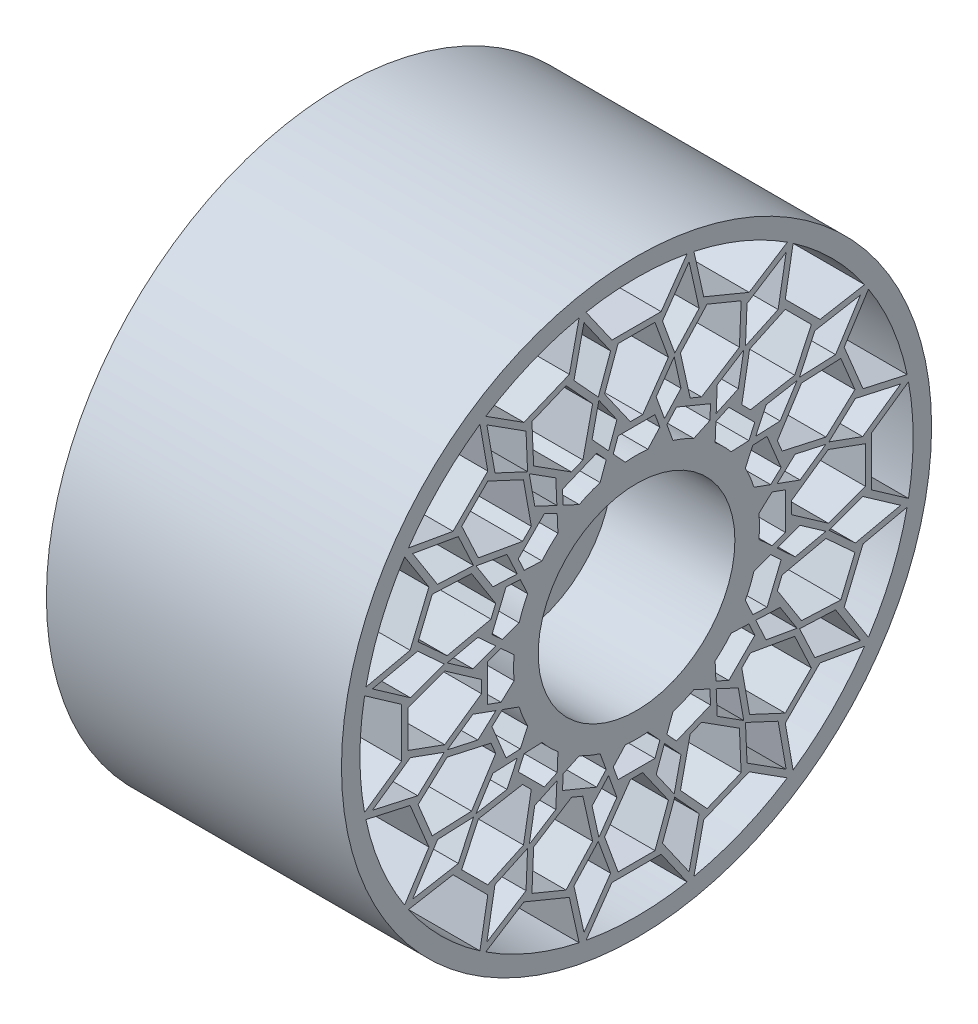
from build123d import *

# Parameters (mm, degrees)
SKETCH1_R           = 152.4
SKETCH1_R_2         = 50.8
BOSS_EXTRUDE3_DEPTH = 63.5
CUT_EXTRUDE1_DEPTH  = 64.5
SKETCH4_R           = 152.4
BOSS_EXTRUDE5_DEPTH = 88.9


with BuildPart() as part:
    # Sketch1 → Boss-Extrude3 (new body)
    with BuildSketch(Plane(origin=(0, 0, 0), x_dir=(0, 0, -1), z_dir=(1, 0, 0))):
        Circle(SKETCH1_R)
        Circle(SKETCH1_R_2, mode=Mode.SUBTRACT)
    extrude(amount=BOSS_EXTRUDE3_DEPTH)

    # Sketch2 → Cut-Extrude1 (cut, through all)
    with BuildSketch(Plane(origin=(63.5, 0, 0), x_dir=(0, 0, -1), z_dir=(1, 0, 0))):
        with BuildLine():
            ThreePointArc((-26.097684485, 140.471265708), (0, 142.875), (26.097684485, 140.471265708))
            Line((26.097684485, 140.471265708), (12.7, 121.337389315))
            Line((12.7, 121.337389315), (-12.7, 121.337389315))
            Line((-12.7, 121.337389315), (-26.097684485, 140.471265708))
        make_face()
        Polygon((3.175, 80.062389315), (-3.175, 80.062389315), (-16.477553736, 99.060404918), (-9.525, 118.162389315), (9.525, 118.162389315), (16.477553736, 99.060404918), align=None)
        with BuildLine():
            Line((9.525, 76.887389315), (-9.525, 76.887389315))
            Line((-9.525, 76.887389315), (-12.031006336, 70.002193495))
            Line((-12.031006336, 70.002193495), (-5.827314658, 63.23205203))
            ThreePointArc((-5.827314658, 63.23205203), (0, 63.5), (5.827314658, 63.23205203))
            Line((5.827314658, 63.23205203), (12.031006336, 70.002193495))
            Line((12.031006336, 70.002193495), (9.525, 76.887389315))
        make_face()
        with BuildLine():
            Line((20.623577502, 74.67974499), (15.673479171, 69.2776606))
            Line((15.673479171, 69.2776606), (18.814121964, 60.648815444))
            ThreePointArc((18.814121964, 60.648815444), (24.300397955, 58.666350314), (29.581595449, 56.188781894))
            Line((29.581595449, 56.188781894), (37.903880189, 60.069527002))
            Line((37.903880189, 60.069527002), (38.223482596, 67.389625603))
            Line((38.223482596, 67.389625603), (20.623577502, 74.67974499))
        make_face()
        Polygon((53.132050408, 85.214193765), (33.571867462, 72.752982915), (27.705232431, 75.18302271), (22.685501123, 97.825567407), (36.418836172, 112.812872694), (54.018741267, 105.522753308), align=None)
        with BuildLine():
            ThreePointArc((29.644909568, 139.765678769), (54.675895399, 131.999288208), (77.867142651, 119.791375818))
            Line((77.867142651, 119.791375818), (58.16707868, 107.241050926))
            Line((58.16707868, 107.241050926), (34.700538554, 116.961210108))
            Line((34.700538554, 116.961210108), (29.644909568, 139.765678769))
        make_face()
        with BuildLine():
            ThreePointArc((80.874334871, 117.782034216), (101.027881362, 101.027881362), (117.782034216, 80.874334871))
            Line((117.782034216, 80.874334871), (94.778746917, 76.818234675))
            Line((94.778746917, 76.818234675), (76.818234675, 94.778746917))
            Line((76.818234675, 94.778746917), (80.874334871, 117.782034216))
        make_face()
        Polygon((81.697674049, 58.39489408), (58.857722433, 54.367594373), (54.367594373, 58.857722433), (58.39489408, 81.697674049), (76.818234675, 90.288618857), (90.288618857, 76.818234675), align=None)
        with BuildLine():
            Line((47.632402282, 61.102786463), (40.991819554, 58.006231883))
            Line((40.991819554, 58.006231883), (40.591279067, 48.83234649))
            ThreePointArc((40.591279067, 48.83234649), (44.901280605, 44.901280605), (48.83234649, 40.591279067))
            Line((48.83234649, 40.591279067), (58.006231883, 40.991819554))
            Line((58.006231883, 40.991819554), (61.102786463, 47.632402282))
            Line((61.102786463, 47.632402282), (47.632402282, 61.102786463))
        make_face()
        Polygon((97.825567407, 22.685501123), (75.18302271, 27.705232431), (72.752982915, 33.571867462), (85.214193765, 53.132050408), (105.522753308, 54.018741267), (112.812872694, 36.418836172), align=None)
        with BuildLine():
            ThreePointArc((119.791375818, 77.867142651), (131.999288208, 54.675895399), (139.765678769, 29.644909568))
            Line((139.765678769, 29.644909568), (116.961210108, 34.700538554))
            Line((116.961210108, 34.700538554), (107.241050926, 58.16707868))
            Line((107.241050926, 58.16707868), (119.791375818, 77.867142651))
        make_face()
        with BuildLine():
            Line((67.389625603, 38.223482596), (60.069527002, 37.903880189))
            Line((60.069527002, 37.903880189), (56.188781894, 29.581595449))
            ThreePointArc((56.188781894, 29.581595449), (58.666350314, 24.300397955), (60.648815444, 18.814121964))
            Line((60.648815444, 18.814121964), (69.2776606, 15.673479171))
            Line((69.2776606, 15.673479171), (74.67974499, 20.623577502))
            Line((74.67974499, 20.623577502), (67.389625603, 38.223482596))
        make_face()
        Polygon((99.060404918, -16.477553736), (80.062389315, -3.175), (80.062389315, 3.175), (99.060404918, 16.477553736), (118.162389315, 9.525), (118.162389315, -9.525), align=None)
        with BuildLine():
            ThreePointArc((140.471265708, 26.097684485), (142.875, 0), (140.471265708, -26.097684485))
            Line((140.471265708, -26.097684485), (121.337389315, -12.7))
            Line((121.337389315, -12.7), (121.337389315, 12.7))
            Line((121.337389315, 12.7), (140.471265708, 26.097684485))
        make_face()
        with BuildLine():
            ThreePointArc((139.765678769, -29.644909568), (131.999288208, -54.675895399), (119.791375818, -77.867142651))
            Line((119.791375818, -77.867142651), (107.241050926, -58.16707868))
            Line((107.241050926, -58.16707868), (116.961210108, -34.700538554))
            Line((116.961210108, -34.700538554), (139.765678769, -29.644909568))
        make_face()
        Polygon((85.214193765, -53.132050408), (72.752982915, -33.571867462), (75.18302271, -27.705232431), (97.825567407, -22.685501123), (112.812872694, -36.418836172), (105.522753308, -54.018741267), align=None)
        with BuildLine():
            Line((74.67974499, -20.623577502), (69.2776606, -15.673479171))
            Line((69.2776606, -15.673479171), (60.648815444, -18.814121964))
            ThreePointArc((60.648815444, -18.814121964), (58.666350314, -24.300397955), (56.188781894, -29.581595449))
            Line((56.188781894, -29.581595449), (60.069527002, -37.903880189))
            Line((60.069527002, -37.903880189), (67.389625603, -38.223482596))
            Line((67.389625603, -38.223482596), (74.67974499, -20.623577502))
        make_face()
        with BuildLine():
            Line((61.102786463, -47.632402282), (58.006231883, -40.991819554))
            Line((58.006231883, -40.991819554), (48.83234649, -40.591279067))
            ThreePointArc((48.83234649, -40.591279067), (44.901280605, -44.901280605), (40.591279067, -48.83234649))
            Line((40.591279067, -48.83234649), (40.991819554, -58.006231883))
            Line((40.991819554, -58.006231883), (47.632402282, -61.102786463))
            Line((47.632402282, -61.102786463), (61.102786463, -47.632402282))
        make_face()
        Polygon((58.39489408, -81.697674049), (54.367594373, -58.857722433), (58.857722433, -54.367594373), (81.697674049, -58.39489408), (90.288618857, -76.818234675), (76.818234675, -90.288618857), align=None)
        Polygon((41.6973225, 74.164905949), (41.147952433, 61.582262732), (52.562564142, 66.904983587), (55.379657648, 82.88151477), align=None)
        Polygon((57.077106506, 102.782099343), (56.266154796, 84.208251511), (73.115814864, 92.065377038), (77.274262751, 115.64910694), align=None)
        Polygon((13.399363914, 116.800740918), (19.758046068, 99.330405283), (32.318310369, 113.037528491), (27.135112552, 136.417422958), align=None)
        Polygon((92.065377038, 73.115814864), (84.208251511, 56.266154796), (102.782099343, 57.077106506), (115.64910694, 77.274262751), align=None)
        Polygon((66.904983587, 52.562564142), (61.582262732, 41.147952433), (74.164905949, 41.6973225), (82.88151477, 55.379657648), align=None)
        Polygon((113.037528491, 32.318310369), (99.330405283, 19.758046068), (116.800740918, 13.399363914), (136.417422958, 27.135112552), align=None)
        Polygon((116.800740918, -13.399363914), (99.330405283, -19.758046068), (113.037528491, -32.318310369), (136.417422958, -27.135112552), align=None)
        Polygon((84.476313131, -10.141622048), (72.641231776, -14.449239382), (81.926967419, -22.958048426), (97.765412591, -19.446749666), align=None)
        Polygon((81.926967419, 22.958048426), (72.641231776, 14.449239382), (84.476313131, 10.141622048), (97.765412591, 19.446749666), align=None)
        with BuildLine():
            Line((76.887389315, 9.525), (70.002193495, 12.031006336))
            Line((70.002193495, 12.031006336), (63.23205203, 5.827314658))
            ThreePointArc((63.23205203, 5.827314658), (63.5, 0), (63.23205203, -5.827314658))
            Line((63.23205203, -5.827314658), (70.002193495, -12.031006336))
            Line((70.002193495, -12.031006336), (76.887389315, -9.525))
            Line((76.887389315, -9.525), (76.887389315, 9.525))
        make_face()
        Polygon((102.782099343, -57.077106506), (84.208251511, -56.266154796), (92.065377038, -73.115814864), (115.64910694, -77.274262751), align=None)
        Polygon((74.164905949, -41.6973225), (61.582262732, -41.147952433), (66.904983587, -52.562564142), (82.88151477, -55.379657648), align=None)
        with BuildLine():
            ThreePointArc((117.782034216, -80.874334871), (101.027881362, -101.027881362), (80.874334871, -117.782034216))
            Line((80.874334871, -117.782034216), (76.818234675, -94.778746917))
            Line((76.818234675, -94.778746917), (94.778746917, -76.818234675))
            Line((94.778746917, -76.818234675), (117.782034216, -80.874334871))
        make_face()
        Polygon((73.115814864, -92.065377038), (56.266154796, -84.208251511), (57.077106506, -102.782099343), (77.274262751, -115.64910694), align=None)
        with BuildLine():
            ThreePointArc((77.867142651, -119.791375818), (54.675895399, -131.999288208), (29.644909568, -139.765678769))
            Line((29.644909568, -139.765678769), (34.700538554, -116.961210108))
            Line((34.700538554, -116.961210108), (58.16707868, -107.241050926))
            Line((58.16707868, -107.241050926), (77.867142651, -119.791375818))
        make_face()
        Polygon((22.685501123, -97.825567407), (27.705232431, -75.18302271), (33.571867462, -72.752982915), (53.132050408, -85.214193765), (54.018741267, -105.522753308), (36.418836172, -112.812872694), align=None)
        Polygon((52.562564142, -66.904983587), (41.147952433, -61.582262732), (41.6973225, -74.164905949), (55.379657648, -82.88151477), align=None)
        with BuildLine():
            Line((38.223482596, -67.389625603), (37.903880189, -60.069527002))
            Line((37.903880189, -60.069527002), (29.581595449, -56.188781894))
            ThreePointArc((29.581595449, -56.188781894), (24.300397955, -58.666350314), (18.814121964, -60.648815444))
            Line((18.814121964, -60.648815444), (15.673479171, -69.2776606))
            Line((15.673479171, -69.2776606), (20.623577502, -74.67974499))
            Line((20.623577502, -74.67974499), (38.223482596, -67.389625603))
        make_face()
        Polygon((22.958048426, -81.926967419), (14.449239382, -72.641231776), (10.141622048, -84.476313131), (19.446749666, -97.765412591), align=None)
        Polygon((32.318310369, -113.037528491), (19.758046068, -99.330405283), (13.399363914, -116.800740918), (27.135112552, -136.417422958), align=None)
        with BuildLine():
            ThreePointArc((26.097684485, -140.471265708), (0, -142.875), (-26.097684485, -140.471265708))
            Line((-26.097684485, -140.471265708), (-12.7, -121.337389315))
            Line((-12.7, -121.337389315), (12.7, -121.337389315))
            Line((12.7, -121.337389315), (26.097684485, -140.471265708))
        make_face()
        Polygon((-16.477553736, -99.060404918), (-3.175, -80.062389315), (3.175, -80.062389315), (16.477553736, -99.060404918), (9.525, -118.162389315), (-9.525, -118.162389315), align=None)
        with BuildLine():
            Line((-5.827314658, -63.23205203), (-12.031006336, -70.002193495))
            Line((-12.031006336, -70.002193495), (-9.525, -76.887389315))
            Line((-9.525, -76.887389315), (9.525, -76.887389315))
            Line((9.525, -76.887389315), (12.031006336, -70.002193495))
            Line((12.031006336, -70.002193495), (5.827314658, -63.23205203))
            ThreePointArc((5.827314658, -63.23205203), (0, -63.5), (-5.827314658, -63.23205203))
        make_face()
        Polygon((-53.132050408, -85.214193765), (-33.571867462, -72.752982915), (-27.705232431, -75.18302271), (-22.685501123, -97.825567407), (-36.418836172, -112.812872694), (-54.018741267, -105.522753308), align=None)
        with BuildLine():
            ThreePointArc((-29.644909568, -139.765678769), (-54.675895399, -131.999288208), (-77.867142651, -119.791375818))
            Line((-77.867142651, -119.791375818), (-58.16707868, -107.241050926))
            Line((-58.16707868, -107.241050926), (-34.700538554, -116.961210108))
            Line((-34.700538554, -116.961210108), (-29.644909568, -139.765678769))
        make_face()
        with BuildLine():
            Line((-29.581595449, -56.188781894), (-37.903880189, -60.069527002))
            Line((-37.903880189, -60.069527002), (-38.223482596, -67.389625603))
            Line((-38.223482596, -67.389625603), (-20.623577502, -74.67974499))
            Line((-20.623577502, -74.67974499), (-15.673479171, -69.2776606))
            Line((-15.673479171, -69.2776606), (-18.814121964, -60.648815444))
            ThreePointArc((-18.814121964, -60.648815444), (-24.300397955, -58.666350314), (-29.581595449, -56.188781894))
        make_face()
        Polygon((-41.6973225, -74.164905949), (-41.147952433, -61.582262732), (-52.562564142, -66.904983587), (-55.379657648, -82.88151477), align=None)
        Polygon((-57.077106506, -102.782099343), (-56.266154796, -84.208251511), (-73.115814864, -92.065377038), (-77.274262751, -115.64910694), align=None)
        with BuildLine():
            ThreePointArc((-80.874334871, -117.782034216), (-101.027881362, -101.027881362), (-117.782034216, -80.874334871))
            Line((-117.782034216, -80.874334871), (-94.778746917, -76.818234675))
            Line((-94.778746917, -76.818234675), (-76.818234675, -94.778746917))
            Line((-76.818234675, -94.778746917), (-80.874334871, -117.782034216))
        make_face()
        Polygon((-81.697674049, -58.39489408), (-58.857722433, -54.367594373), (-54.367594373, -58.857722433), (-58.39489408, -81.697674049), (-76.818234675, -90.288618857), (-90.288618857, -76.818234675), align=None)
        with BuildLine():
            Line((-48.83234649, -40.591279067), (-58.006231883, -40.991819554))
            Line((-58.006231883, -40.991819554), (-61.102786463, -47.632402282))
            Line((-61.102786463, -47.632402282), (-47.632402282, -61.102786463))
            Line((-47.632402282, -61.102786463), (-40.991819554, -58.006231883))
            Line((-40.991819554, -58.006231883), (-40.591279067, -48.83234649))
            ThreePointArc((-40.591279067, -48.83234649), (-44.901280605, -44.901280605), (-48.83234649, -40.591279067))
        make_face()
        Polygon((-66.904983587, -52.562564142), (-61.582262732, -41.147952433), (-74.164905949, -41.6973225), (-82.88151477, -55.379657648), align=None)
        Polygon((-92.065377038, -73.115814864), (-84.208251511, -56.266154796), (-102.782099343, -57.077106506), (-115.64910694, -77.274262751), align=None)
        with BuildLine():
            ThreePointArc((-119.791375818, -77.867142651), (-131.999288208, -54.675895399), (-139.765678769, -29.644909568))
            Line((-139.765678769, -29.644909568), (-116.961210108, -34.700538554))
            Line((-116.961210108, -34.700538554), (-107.241050926, -58.16707868))
            Line((-107.241050926, -58.16707868), (-119.791375818, -77.867142651))
        make_face()
        Polygon((-97.825567407, -22.685501123), (-75.18302271, -27.705232431), (-72.752982915, -33.571867462), (-85.214193765, -53.132050408), (-105.522753308, -54.018741267), (-112.812872694, -36.418836172), align=None)
        with BuildLine():
            Line((-60.648815444, -18.814121964), (-69.2776606, -15.673479171))
            Line((-69.2776606, -15.673479171), (-74.67974499, -20.623577502))
            Line((-74.67974499, -20.623577502), (-67.389625603, -38.223482596))
            Line((-67.389625603, -38.223482596), (-60.069527002, -37.903880189))
            Line((-60.069527002, -37.903880189), (-56.188781894, -29.581595449))
            ThreePointArc((-56.188781894, -29.581595449), (-58.666350314, -24.300397955), (-60.648815444, -18.814121964))
        make_face()
        Polygon((-81.926967419, -22.958048426), (-72.641231776, -14.449239382), (-84.476313131, -10.141622048), (-97.765412591, -19.446749666), align=None)
        Polygon((-113.037528491, -32.318310369), (-99.330405283, -19.758046068), (-116.800740918, -13.399363914), (-136.417422958, -27.135112552), align=None)
        with BuildLine():
            ThreePointArc((-140.471265708, -26.097684485), (-142.875, 0), (-140.471265708, 26.097684485))
            Line((-140.471265708, 26.097684485), (-121.337389315, 12.7))
            Line((-121.337389315, 12.7), (-121.337389315, -12.7))
            Line((-121.337389315, -12.7), (-140.471265708, -26.097684485))
        make_face()
        Polygon((-99.060404918, 16.477553736), (-80.062389315, 3.175), (-80.062389315, -3.175), (-99.060404918, -16.477553736), (-118.162389315, -9.525), (-118.162389315, 9.525), align=None)
        with BuildLine():
            Line((-63.23205203, 5.827314658), (-70.002193495, 12.031006336))
            Line((-70.002193495, 12.031006336), (-76.887389315, 9.525))
            Line((-76.887389315, 9.525), (-76.887389315, -9.525))
            Line((-76.887389315, -9.525), (-70.002193495, -12.031006336))
            Line((-70.002193495, -12.031006336), (-63.23205203, -5.827314658))
            ThreePointArc((-63.23205203, -5.827314658), (-63.5, 0), (-63.23205203, 5.827314658))
        make_face()
        Polygon((-84.476313131, 10.141622048), (-72.641231776, 14.449239382), (-81.926967419, 22.958048426), (-97.765412591, 19.446749666), align=None)
        Polygon((-116.800740918, 13.399363914), (-99.330405283, 19.758046068), (-113.037528491, 32.318310369), (-136.417422958, 27.135112552), align=None)
        with BuildLine():
            ThreePointArc((-139.765678769, 29.644909568), (-131.999288208, 54.675895399), (-119.791375818, 77.867142651))
            Line((-119.791375818, 77.867142651), (-107.241050926, 58.16707868))
            Line((-107.241050926, 58.16707868), (-116.961210108, 34.700538554))
            Line((-116.961210108, 34.700538554), (-139.765678769, 29.644909568))
        make_face()
        Polygon((-85.214193765, 53.132050408), (-72.752982915, 33.571867462), (-75.18302271, 27.705232431), (-97.825567407, 22.685501123), (-112.812872694, 36.418836172), (-105.522753308, 54.018741267), align=None)
        with BuildLine():
            Line((-56.188781894, 29.581595449), (-60.069527002, 37.903880189))
            Line((-60.069527002, 37.903880189), (-67.389625603, 38.223482596))
            Line((-67.389625603, 38.223482596), (-74.67974499, 20.623577502))
            Line((-74.67974499, 20.623577502), (-69.2776606, 15.673479171))
            Line((-69.2776606, 15.673479171), (-60.648815444, 18.814121964))
            ThreePointArc((-60.648815444, 18.814121964), (-58.666350314, 24.300397955), (-56.188781894, 29.581595449))
        make_face()
        Polygon((-74.164905949, 41.6973225), (-61.582262732, 41.147952433), (-66.904983587, 52.562564142), (-82.88151477, 55.379657648), align=None)
        Polygon((-102.782099343, 57.077106506), (-84.208251511, 56.266154796), (-92.065377038, 73.115814864), (-115.64910694, 77.274262751), align=None)
        with BuildLine():
            ThreePointArc((-117.782034216, 80.874334871), (-101.027881362, 101.027881362), (-80.874334871, 117.782034216))
            Line((-80.874334871, 117.782034216), (-76.818234675, 94.778746917))
            Line((-76.818234675, 94.778746917), (-94.778746917, 76.818234675))
            Line((-94.778746917, 76.818234675), (-117.782034216, 80.874334871))
        make_face()
        Polygon((-58.39489408, 81.697674049), (-54.367594373, 58.857722433), (-58.857722433, 54.367594373), (-81.697674049, 58.39489408), (-90.288618857, 76.818234675), (-76.818234675, 90.288618857), align=None)
        with BuildLine():
            Line((-40.591279067, 48.83234649), (-40.991819554, 58.006231883))
            Line((-40.991819554, 58.006231883), (-47.632402282, 61.102786463))
            Line((-47.632402282, 61.102786463), (-61.102786463, 47.632402282))
            Line((-61.102786463, 47.632402282), (-58.006231883, 40.991819554))
            Line((-58.006231883, 40.991819554), (-48.83234649, 40.591279067))
            ThreePointArc((-48.83234649, 40.591279067), (-44.901280605, 44.901280605), (-40.591279067, 48.83234649))
        make_face()
        Polygon((-52.562564142, 66.904983587), (-41.147952433, 61.582262732), (-41.6973225, 74.164905949), (-55.379657648, 82.88151477), align=None)
        Polygon((-73.115814864, 92.065377038), (-56.266154796, 84.208251511), (-57.077106506, 102.782099343), (-77.274262751, 115.64910694), align=None)
        with BuildLine():
            ThreePointArc((-77.867142651, 119.791375818), (-54.675895399, 131.999288208), (-29.644909568, 139.765678769))
            Line((-29.644909568, 139.765678769), (-34.700538554, 116.961210108))
            Line((-34.700538554, 116.961210108), (-58.16707868, 107.241050926))
            Line((-58.16707868, 107.241050926), (-77.867142651, 119.791375818))
        make_face()
        Polygon((-22.685501123, 97.825567407), (-27.705232431, 75.18302271), (-33.571867462, 72.752982915), (-53.132050408, 85.214193765), (-54.018741267, 105.522753308), (-36.418836172, 112.812872694), align=None)
        with BuildLine():
            Line((-18.814121964, 60.648815444), (-15.673479171, 69.2776606))
            Line((-15.673479171, 69.2776606), (-20.623577502, 74.67974499))
            Line((-20.623577502, 74.67974499), (-38.223482596, 67.389625603))
            Line((-38.223482596, 67.389625603), (-37.903880189, 60.069527002))
            Line((-37.903880189, 60.069527002), (-29.581595449, 56.188781894))
            ThreePointArc((-29.581595449, 56.188781894), (-24.300397955, 58.666350314), (-18.814121964, 60.648815444))
        make_face()
        Polygon((-22.958048426, 81.926967419), (-14.449239382, 72.641231776), (-10.141622048, 84.476313131), (-19.446749666, 97.765412591), align=None)
        Polygon((-32.318310369, 113.037528491), (-19.758046068, 99.330405283), (-13.399363914, 116.800740918), (-27.135112552, 136.417422958), align=None)
        Polygon((-13.399363914, -116.800740918), (-19.758046068, -99.330405283), (-32.318310369, -113.037528491), (-27.135112552, -136.417422958), align=None)
        Polygon((-10.141622048, -84.476313131), (-14.449239382, -72.641231776), (-22.958048426, -81.926967419), (-19.446749666, -97.765412591), align=None)
        Polygon((10.141622048, 84.476313131), (14.449239382, 72.641231776), (22.958048426, 81.926967419), (19.446749666, 97.765412591), align=None)
    extrude(amount=-CUT_EXTRUDE1_DEPTH, mode=Mode.SUBTRACT)

    # Sketch4 → Boss-Extrude5 (add)
    with BuildSketch(Plane.ZY):
        Circle(SKETCH4_R)
    extrude(amount=BOSS_EXTRUDE5_DEPTH)


solid = part.part
